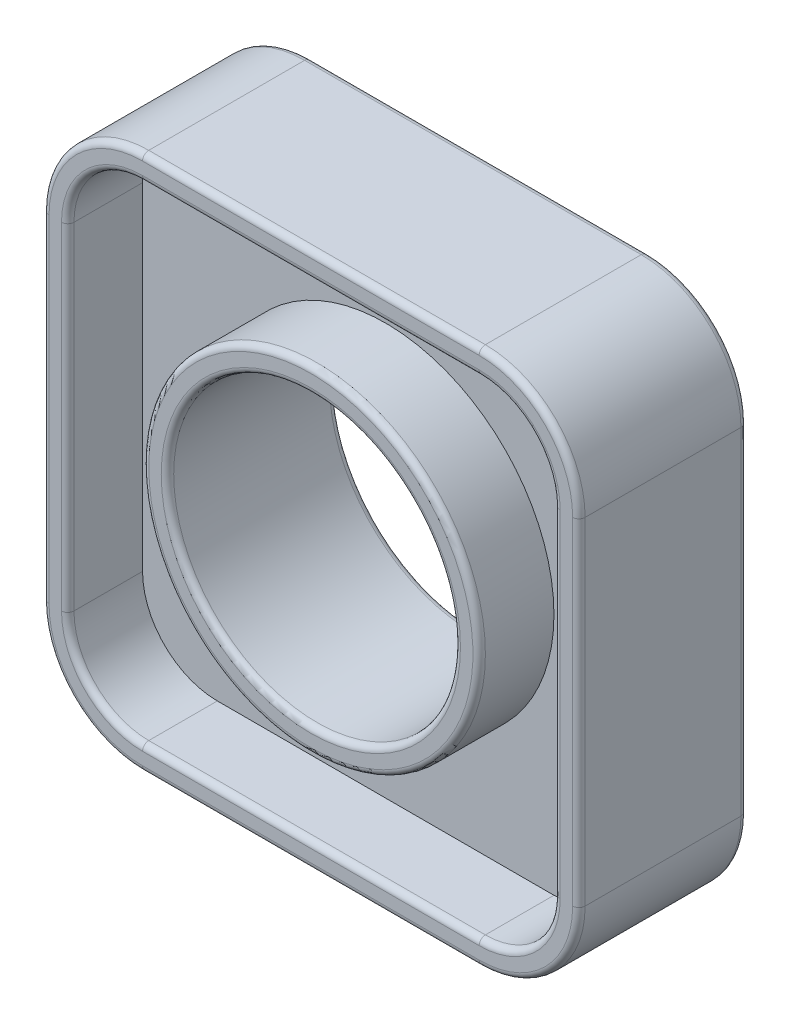
from build123d import *

# Parameters (mm, degrees)
EXTRUDE_1_DEPTH     = 13.5
CUT_EXTRUDE_1_DEPTH = 6
CUT_EXTRUDE_2_DEPTH = 6
EXTRUDE_START       = -7.5
SKETCH_4_R          = 13.5
EXTRUDE_2_DEPTH     = 13.5
CUT_EXTRUDE_3_REACH = 15.5
SKETCH_5_R          = 11.5
FILLET_1_R          = 0.5


with BuildPart() as part:
    # 草圖1 → 填料-伸長1 (new body)
    with BuildSketch(Plane.XY):
        with BuildLine():
            Line((-13.5, -21.5), (13.5, -21.5))
            ThreePointArc((13.5, -21.5), (19.156854249, -19.156854249), (21.5, -13.5))
            Line((21.5, -13.5), (21.5, 13.5))
            ThreePointArc((21.5, 13.5), (19.156854249, 19.156854249), (13.5, 21.5))
            Line((13.5, 21.5), (-13.5, 21.5))
            ThreePointArc((-13.5, 21.5), (-19.156854249, 19.156854249), (-21.5, 13.5))
            Line((-21.5, 13.5), (-21.5, -13.5))
            ThreePointArc((-21.5, -13.5), (-19.156854249, -19.156854249), (-13.5, -21.5))
        make_face()
    extrude(amount=EXTRUDE_1_DEPTH)

    # 草圖2 → 除料-伸長1 (cut)
    with BuildSketch(Plane.XY.offset(13.5)):
        with BuildLine():
            Line((-13.5, -19.5), (13.5, -19.5))
            ThreePointArc((13.5, -19.5), (17.742640687, -17.742640687), (19.5, -13.5))
            Line((19.5, -13.5), (19.5, 13.5))
            ThreePointArc((19.5, 13.5), (17.742640687, 17.742640687), (13.5, 19.5))
            Line((13.5, 19.5), (-13.5, 19.5))
            ThreePointArc((-13.5, 19.5), (-17.742640687, 17.742640687), (-19.5, 13.5))
            Line((-19.5, 13.5), (-19.5, -13.5))
            ThreePointArc((-19.5, -13.5), (-17.742640687, -17.742640687), (-13.5, -19.5))
        make_face()
    extrude(amount=-CUT_EXTRUDE_1_DEPTH, mode=Mode.SUBTRACT)

    # 草圖3 → 除料-伸長2 (cut)
    with BuildSketch(Plane(origin=(0, 0, 0), x_dir=(-1, 0, 0), z_dir=(0, 0, -1))):
        with BuildLine():
            Line((19.5, -13.5), (19.5, 13.5))
            ThreePointArc((19.5, 13.5), (17.742640687, 17.742640687), (13.5, 19.5))
            Line((13.5, 19.5), (-13.5, 19.5))
            ThreePointArc((-13.5, 19.5), (-17.742640687, 17.742640687), (-19.5, 13.5))
            Line((-19.5, 13.5), (-19.5, -13.5))
            ThreePointArc((-19.5, -13.5), (-17.742640687, -17.742640687), (-13.5, -19.5))
            Line((-13.5, -19.5), (13.5, -19.5))
            ThreePointArc((13.5, -19.5), (17.742640687, -17.742640687), (19.5, -13.5))
        make_face()
    extrude(amount=-CUT_EXTRUDE_2_DEPTH, mode=Mode.SUBTRACT)

    # 草圖4 → 填料-伸長2 (add)
    with BuildSketch(Plane(origin=(0, 0, 6), x_dir=(-1, 0, 0), z_dir=(0, 0, -1)).offset(EXTRUDE_START)):
        Circle(SKETCH_4_R)
    extrude(amount=EXTRUDE_2_DEPTH)

    # 草圖5 → 除料-伸長3 (cut, up to next)
    with BuildSketch(Plane.XY.offset(13.5), mode=Mode.PRIVATE) as cut_extrude_3_sk1:
        Circle(SKETCH_5_R)
    cut_extrude_3_tool1 = extrude(cut_extrude_3_sk1.sketch, amount=-CUT_EXTRUDE_3_REACH, mode=Mode.PRIVATE) & part.part
    add(cut_extrude_3_tool1.solids().sort_by_distance((0, 0, 13.5))[0], mode=Mode.SUBTRACT)

    # 圓角1
    fillet_1_edges = [part.edges().sort_by_distance(p)[0] for p in [
        (21.5, 0, 0),
        (19.156854249, -19.156854249, 0),
        (0, -21.5, 0),
        (-19.156854249, -19.156854249, 0),
        (19.156854249, -19.156854249, 13.5),
        (21.5, 0, 13.5),
        (19.156854249, 19.156854249, 13.5),
        (0, 21.5, 13.5),
        (-19.156854249, 19.156854249, 13.5),
        (-17.742640687, -17.742640687, 13.5),
        (0, -19.5, 13.5),
        (17.742640687, -17.742640687, 13.5),
        (19.5, 0, 13.5),
        (17.742640687, 17.742640687, 13.5),
        (-21.5, 0, 13.5),
        (0, 19.5, 13.5),
        (-17.742640687, 17.742640687, 13.5),
        (-19.5, 0, 13.5),
        (-19.156854249, -19.156854249, 13.5),
        (-17.742640687, -17.742640687, 0),
        (-19.5, 0, 0),
        (-17.742640687, 17.742640687, 0),
        (0, 19.5, 0),
        (17.742640687, 17.742640687, 0),
        (19.5, 0, 0),
        (17.742640687, -17.742640687, 0),
        (0, -19.5, 0),
        (13.5, 0, 0),
        (13.5, 0, 13.5),
        (-11.5, 0, 0),
        (-11.5, 0, 13.5),
        (-21.5, 0, 0),
        (0, -21.5, 13.5),
        (-19.156854249, 19.156854249, 0),
        (0, 21.5, 0),
        (19.156854249, 19.156854249, 0),
    ]]
    fillet(fillet_1_edges, radius=FILLET_1_R)


solid = part.part
